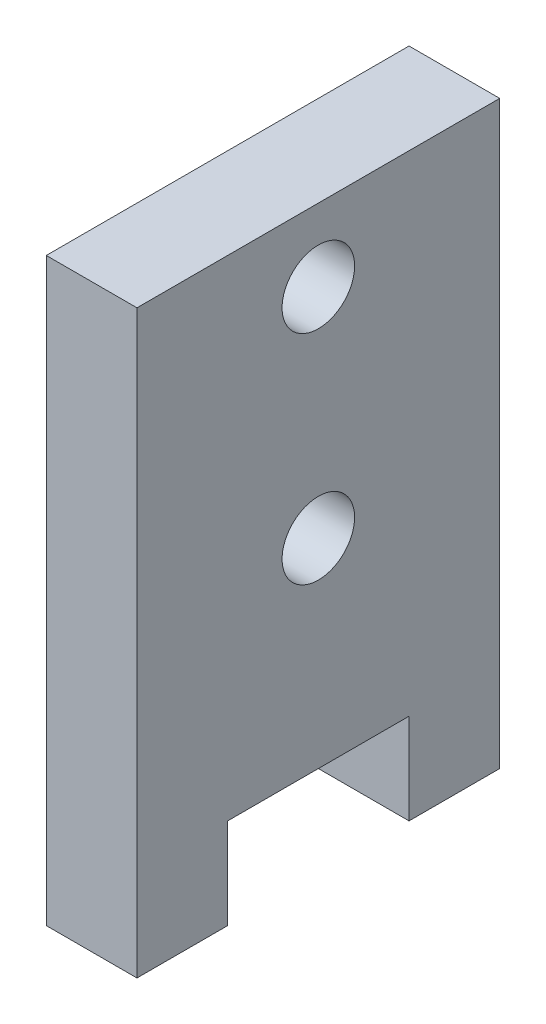
from build123d import *

# Parameters (mm, degrees)
SKETCH1_W           = 12.7
SKETCH1_H           = 20.32
BOSS_EXTRUDE1_DEPTH = 3.175
SKETCH2_W           = 6.35
SKETCH2_H           = 3.175
CUT_EXTRUDE1_DEPTH  = 4.175
SKETCH3_R           = 1.27
CUT_EXTRUDE2_DEPTH  = 4.175


with BuildPart() as part:
    # Sketch1 → Boss-Extrude1 (new body)
    with BuildSketch(Plane(origin=(0, 0, 0), x_dir=(0, 0, -1), z_dir=(1, 0, 0))):
        Rectangle(SKETCH1_W, SKETCH1_H)
    extrude(amount=BOSS_EXTRUDE1_DEPTH)

    # Sketch2 → Cut-Extrude1 (cut, through all)
    with BuildSketch(Plane(origin=(3.175, 0, 0), x_dir=(0, 0, -1), z_dir=(1, 0, 0))):
        with Locations((0, -8.5725)):
            Rectangle(SKETCH2_W, SKETCH2_H)
    extrude(amount=-CUT_EXTRUDE1_DEPTH, mode=Mode.SUBTRACT)

    # Sketch3 → Cut-Extrude2 (cut, through all)
    with BuildSketch(Plane(origin=(3.175, 0, 0), x_dir=(0, 0, -1), z_dir=(1, 0, 0))):
        Circle(SKETCH3_R)
        with Locations((0, 7.62)):
            Circle(SKETCH3_R)
    extrude(amount=-CUT_EXTRUDE2_DEPTH, mode=Mode.SUBTRACT)


solid = part.part
